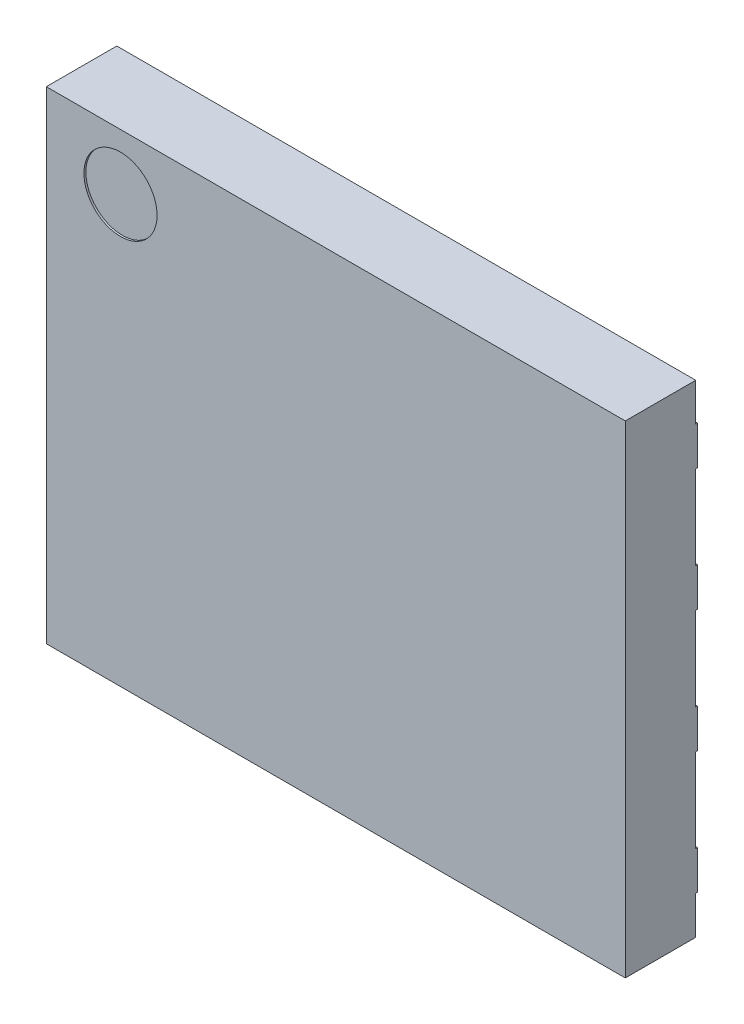
from build123d import *

# Parameters (mm, degrees)
BOSS_EXTRUDE1_START  = 0.02
SKETCH1_W            = 6
SKETCH1_H            = 5
BOSS_EXTRUDE1_DEPTH  = 0.73
BOSS_EXTRUDE2_DEPTH  = 0.02
BOSS_EXTRUDE3_DEPTH  = 0.02
LPATTERN1_COUNT      = 4
LPATTERN1_PITCH      = 1.27
MIRROR1_COPY_1_DEPTH = 0.02
MIRROR1_COPY_2_DEPTH = 0.02
MIRROR1_COPY_3_DEPTH = 0.02
SKETCH4_R            = 0.378837043
CUT_EXTRUDE1_DEPTH   = 0.02


with BuildPart() as part:
    # Sketch1 → Boss-Extrude1 (new body)
    with BuildSketch(Plane.XY.offset(BOSS_EXTRUDE1_START)):
        Rectangle(SKETCH1_W, SKETCH1_H)
    extrude(amount=BOSS_EXTRUDE1_DEPTH)

    # Sketch2 → Boss-Extrude2 (add)
    with BuildSketch(Plane.XY):
        Polygon((-1.7, -2.15), (1.7, -2.15), (1.7, 2.15), (-1.1, 2.15), (-1.7, 1.55), align=None)
    extrude(amount=BOSS_EXTRUDE2_DEPTH)

    # Sketch3 → Boss-Extrude3 (add)
    with BuildSketch(Plane.XY):
        with BuildLine():
            Line((-3, 2.105), (-2.4, 2.105))
            ThreePointArc((-2.4, 2.105), (-2.2, 1.905), (-2.4, 1.705))
            Line((-2.4, 1.705), (-3, 1.705))
            Line((-3, 1.705), (-3, 2.105))
        make_face()
    boss_extrude3 = extrude(amount=BOSS_EXTRUDE3_DEPTH)

    # LPattern1: Boss-Extrude3 ×4
    with Locations(*[(0, -i * LPATTERN1_PITCH, 0) for i in range(1, LPATTERN1_COUNT)]):
        add(boss_extrude3)

    # Mirror1: Boss-Extrude3 across plane
    add(boss_extrude3.mirror(Plane(origin=(0, 0, 0), x_dir=(0, 0, 1), z_dir=(1, 0, 0))))

    # Mirror1 copy 1 sketch → Mirror1 copy 1 (add)
    with BuildSketch(Plane(origin=(0, -1.27, 0), x_dir=(-1, 0, 0), z_dir=(0, 0, 1))):
        with BuildLine():
            Line((-3, -2.105), (-2.4, -2.105))
            ThreePointArc((-2.4, -2.105), (-2.2, -1.905), (-2.4, -1.705))
            Line((-2.4, -1.705), (-3, -1.705))
            Line((-3, -1.705), (-3, -2.105))
        make_face()
    extrude(amount=MIRROR1_COPY_1_DEPTH)

    # Mirror1 copy 2 sketch → Mirror1 copy 2 (add)
    with BuildSketch(Plane(origin=(0, -2.54, 0), x_dir=(-1, 0, 0), z_dir=(0, 0, 1))):
        with BuildLine():
            Line((-3, -2.105), (-2.4, -2.105))
            ThreePointArc((-2.4, -2.105), (-2.2, -1.905), (-2.4, -1.705))
            Line((-2.4, -1.705), (-3, -1.705))
            Line((-3, -1.705), (-3, -2.105))
        make_face()
    extrude(amount=MIRROR1_COPY_2_DEPTH)

    # Mirror1 copy 3 sketch → Mirror1 copy 3 (add)
    with BuildSketch(Plane(origin=(0, -3.81, 0), x_dir=(-1, 0, 0), z_dir=(0, 0, 1))):
        with BuildLine():
            Line((-3, -2.105), (-2.4, -2.105))
            ThreePointArc((-2.4, -2.105), (-2.2, -1.905), (-2.4, -1.705))
            Line((-2.4, -1.705), (-3, -1.705))
            Line((-3, -1.705), (-3, -2.105))
        make_face()
    extrude(amount=MIRROR1_COPY_3_DEPTH)

    # Sketch4 → Cut-Extrude1 (cut)
    with BuildSketch(Plane.XY.offset(0.75)):
        with Locations((-2.231694583, 1.918293029)):
            Circle(SKETCH4_R)
    extrude(amount=-CUT_EXTRUDE1_DEPTH, mode=Mode.SUBTRACT)


solid = part.part
